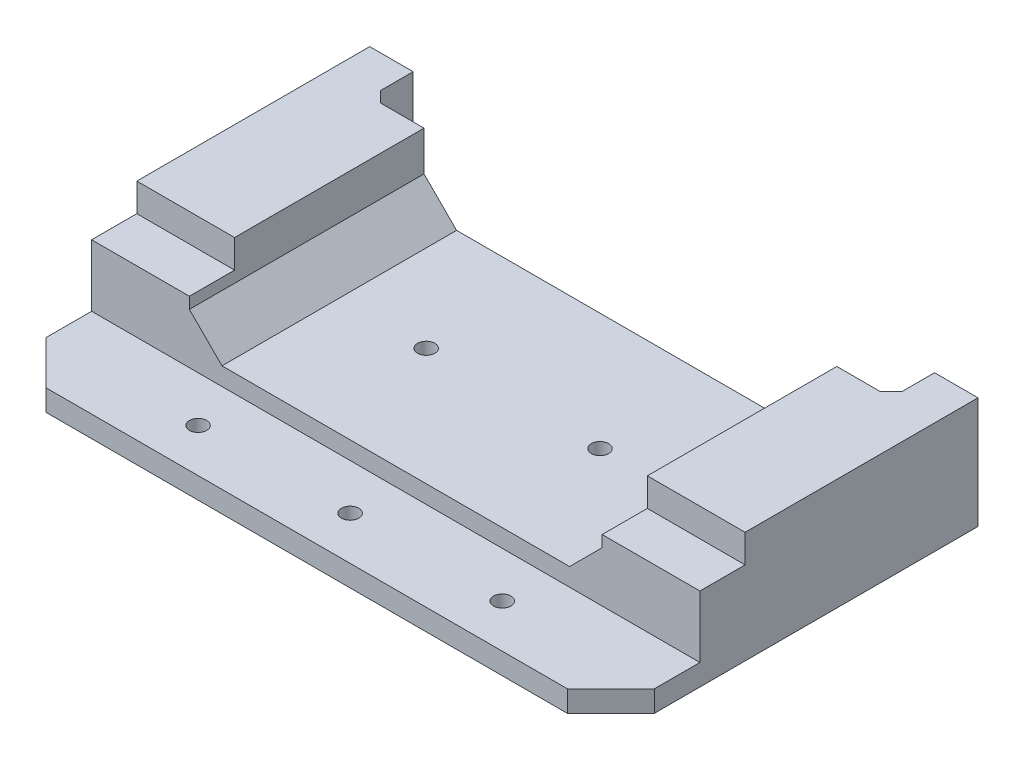
from build123d import *

# Parameters (mm, degrees)
SKETCH1_W                      = 177.8
SKETCH1_H                      = 35.749524071
BOSS_EXTRUDE1_DEPTH            = 15.24
SKETCH2_W                      = 177.8
SKETCH2_H                      = 107.315000048
BOSS_EXTRUDE2_DEPTH            = 6.222024
CHAMFER1_SIZE                  = 12.7
F_8_0_199_DIAMETER_HOLE2_D     = 5.0546
CUT_EXTRUDE1_DEPTH             = 82.280000048
SKETCH8_W                      = 177.8
SKETCH8_H                      = 29.5275
BOSS_EXTRUDE3_DEPTH            = 66.04
SKETCH9_W                      = 152.4
SKETCH9_H                      = 12.7
CUT_EXTRUDE2_DEPTH             = 36.749524071
SKETCH10_W                     = 177.8
SKETCH10_H                     = 3.175
CUT_EXTRUDE3_DEPTH             = 108.315000048
SKETCH11_W                     = 13.208
SKETCH11_H                     = 8.255
CUT_EXTRUDE4_DEPTH             = 178.8
SKETCH12_W                     = 120.65
SKETCH12_H                     = 11.58875
CUT_EXTRUDE5_DEPTH             = 95.615000048
BOSS_EXTRUDE4_DEPTH            = 68.58
CHAMFER2_SIZE                  = 3.175
F_8_0_199_DIAMETER_HOLE1_D     = 5.0546
F_8_0_199_DIAMETER_HOLE1_DEPTH = 11.460774071
F_8_PLASTIC_INSERT_AT_2_COUNT  = 2
F_8_PLASTIC_INSERT_AT_2_PITCH  = 50.8


with BuildPart() as part:
    # Sketch1 → Boss-Extrude1 (new body)
    with BuildSketch(Plane.XY):
        with Locations((0, 59.912737965)):
            Rectangle(SKETCH1_W, SKETCH1_H)
    extrude(amount=BOSS_EXTRUDE1_DEPTH)

    # Sketch2 → Boss-Extrude2 (add)
    with BuildSketch(Plane.XZ.offset(-42.037975929)):
        with Locations((0, -12.382499976)):
            Rectangle(SKETCH2_W, SKETCH2_H)
    extrude(amount=-BOSS_EXTRUDE2_DEPTH)

    # Chamfer1
    chamfer1_edges = [part.edges().sort_by_distance(p)[0] for p in [
        (88.9, 45.148987929, 41.275000048),
        (-88.9, 45.148987929, 41.275000048),
    ]]
    chamfer(chamfer1_edges, length=CHAMFER1_SIZE)

    # #8 (0.199) Diameter Hole2 (through all)
    with Locations(Plane(origin=(0, 42.037975929, 0), x_dir=(-1, 0, 0), z_dir=(0, -1, 0))):
        with Locations((-44.45, -28.575000048), (0, -28.575000048), (44.45, -28.575000048)):
            Hole(F_8_0_199_DIAMETER_HOLE2_D / 2)

    # Sketch7 → Cut-Extrude1 (cut, through all)
    with BuildSketch(Plane.XY.offset(15.240000048)):
        with BuildLine():
            Line((-50.8, 72.54875), (50.8, 72.54875))
            ThreePointArc((50.8, 72.54875), (60.325, 63.02375), (50.8, 53.49875))
            Line((50.8, 53.49875), (-50.8, 53.49875))
            ThreePointArc((-50.8, 53.49875), (-60.325, 63.02375), (-50.8, 72.54875))
        make_face()
    extrude(amount=-CUT_EXTRUDE1_DEPTH, mode=Mode.SUBTRACT)

    # Sketch8 → Boss-Extrude3 (add)
    with BuildSketch(Plane(origin=(0, 0, 0), x_dir=(-1, 0, 0), z_dir=(0, 0, -1))):
        with Locations((0, 63.02375)):
            Rectangle(SKETCH8_W, SKETCH8_H)
        with BuildLine():
            Line((50.8, 72.54875), (-50.8, 72.54875))
            ThreePointArc((-50.8, 72.54875), (-60.325, 63.02375), (-50.8, 53.49875))
            Line((-50.8, 53.49875), (50.8, 53.49875))
            ThreePointArc((50.8, 53.49875), (60.325, 63.02375), (50.8, 72.54875))
        make_face(mode=Mode.SUBTRACT)
    extrude(amount=BOSS_EXTRUDE3_DEPTH)

    # Sketch9 → Cut-Extrude2 (cut, through all)
    with BuildSketch(Plane.XZ.offset(-42.037975929)):
        with Locations((0, -59.69)):
            Rectangle(SKETCH9_W, SKETCH9_H)
    extrude(amount=-CUT_EXTRUDE2_DEPTH, mode=Mode.SUBTRACT)

    # Sketch10 → Cut-Extrude3 (cut, through all)
    with BuildSketch(Plane(origin=(0, 0, -66.04), x_dir=(-1, 0, 0), z_dir=(0, 0, -1))):
        with Locations((0, 76.2)):
            Rectangle(SKETCH10_W, SKETCH10_H)
    extrude(amount=-CUT_EXTRUDE3_DEPTH, mode=Mode.SUBTRACT)

    # Sketch11 → Cut-Extrude4 (cut, through all)
    with BuildSketch(Plane(origin=(88.9, 0, 0), x_dir=(0, 0, -1), z_dir=(1, 0, 0))):
        with Locations((-8.636000048, 70.485)):
            Rectangle(SKETCH11_W, SKETCH11_H)
    extrude(amount=-CUT_EXTRUDE4_DEPTH, mode=Mode.SUBTRACT)

    # Sketch12 → Cut-Extrude5 (cut, through all)
    with BuildSketch(Plane(origin=(0, 0, -53.34), x_dir=(-1, 0, 0), z_dir=(0, 0, -1))):
        with Locations((0, 68.818125)):
            Rectangle(SKETCH12_W, SKETCH12_H)
    extrude(amount=-CUT_EXTRUDE5_DEPTH, mode=Mode.SUBTRACT)

    # Sketch13 → Boss-Extrude4 (add)
    with BuildSketch(Plane.XY.offset(15.240000048)):
        with BuildLine():
            Line((60.325, 63.02375), (50.8, 53.49875))
            ThreePointArc((50.8, 53.49875), (57.535192091, 56.288557909), (60.325, 63.02375))
        make_face()
        with BuildLine():
            Line((-60.325, 63.02375), (-50.8, 53.49875))
            ThreePointArc((-50.8, 53.49875), (-57.535192091, 56.288557909), (-60.325, 63.02375))
        make_face()
    extrude(amount=-BOSS_EXTRUDE4_DEPTH)

    # Chamfer2
    chamfer2_edges = [part.edges().sort_by_distance(p)[0] for p in [
        (-76.2, 58.325237965, -53.34),
        (76.2, 58.325237965, -53.34),
    ]]
    chamfer(chamfer2_edges, length=CHAMFER2_SIZE)

    # #8 (0.199) Diameter Hole1
    with Locations(Plane(origin=(9.884621419, 42.037975929, -19.494996768), x_dir=(-1, 0, 0), z_dir=(0, -1, 0))):
        with Locations((-15.515378581, -0.444996793), (35.284621419, -0.444996793)):
            Hole(F_8_0_199_DIAMETER_HOLE1_D / 2, depth=F_8_0_199_DIAMETER_HOLE1_DEPTH)

    # Sketch51 → #8 Plastic Insert (revolve, cut)
    with BuildSketch(Plane(origin=(25.4, 42.037975929, -19.049999976), x_dir=(0, 0, -1), z_dir=(1, 0, 0))):
        Polygon((0, 0), (0, 4.699), (2.8702, 4.699), (2.9972, 0), align=None)
    f_8_plastic_insert = revolve(axis=Axis((25.4, 152.037975929, -19.049999976), (0, -1, 0)), mode=Mode.SUBTRACT)

    # #8 Plastic Insert at 2: #8 Plastic Insert ×2
    with Locations(*[(-i * F_8_PLASTIC_INSERT_AT_2_PITCH, 0, 0) for i in range(1, F_8_PLASTIC_INSERT_AT_2_COUNT)]):
        add(f_8_plastic_insert, mode=Mode.SUBTRACT)


solid = part.part
